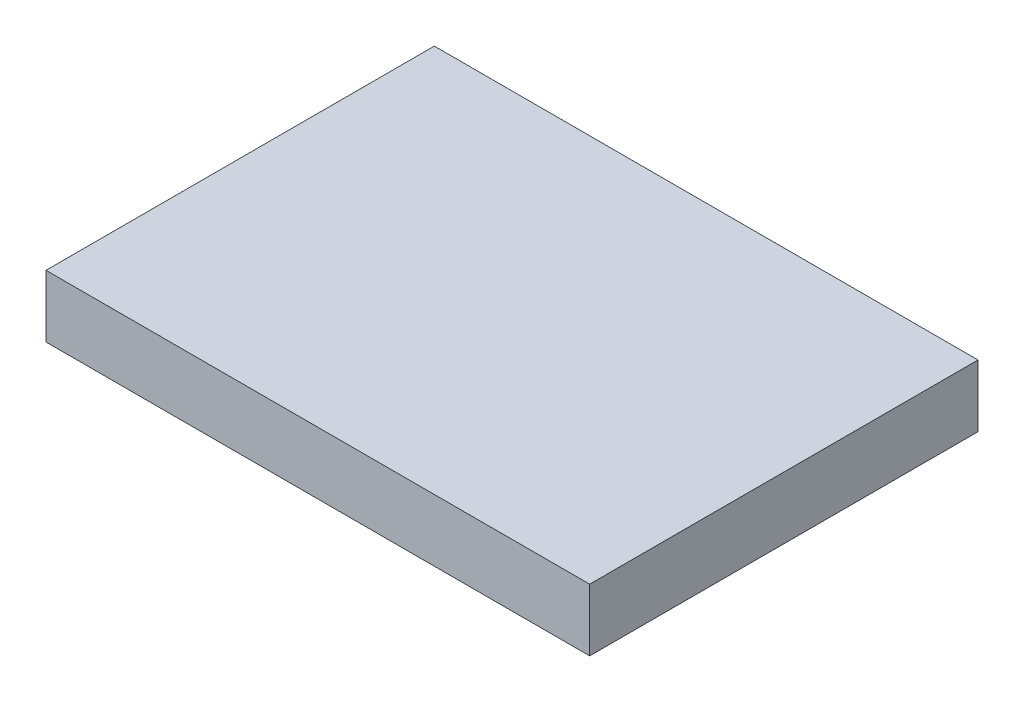
from build123d import *

# Parameters (mm, degrees)
SKETCH_1_W      = 17.5
SKETCH_1_H      = 12.5
EXTRUDE_1_DEPTH = 2


with BuildPart() as part:
    # 草图1 → 凸台-拉伸1 (new body)
    with BuildSketch(Plane(origin=(0, 0, 0), x_dir=(1, 0, 0), z_dir=(0, 1, 0))):
        Rectangle(SKETCH_1_W, SKETCH_1_H)
    extrude(amount=EXTRUDE_1_DEPTH)


solid = part.part
